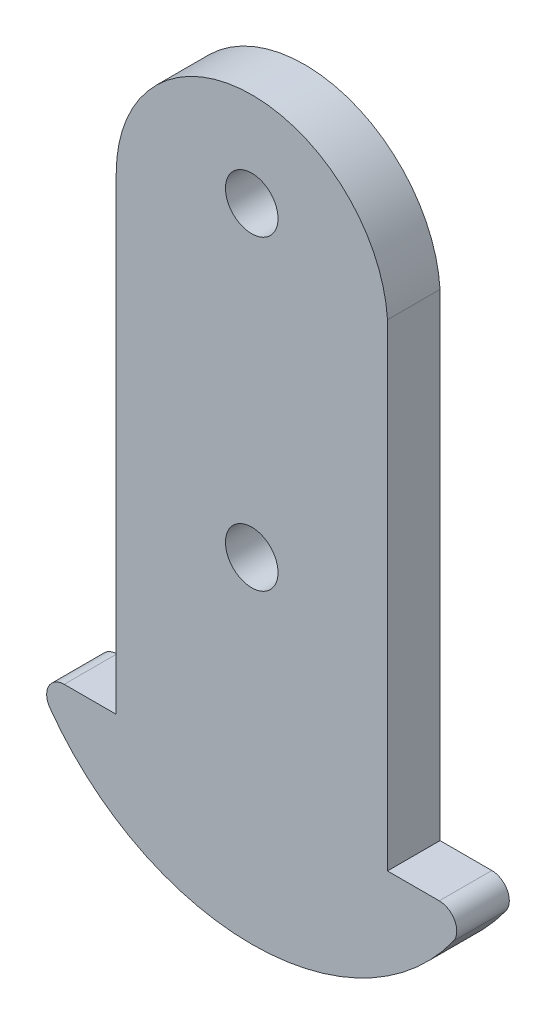
from build123d import *

# Parameters (mm, degrees)
SKETCH1_R           = 1.5
BOSS_EXTRUDE2_DEPTH = 3


with BuildPart() as part:
    # Sketch1 → Boss-Extrude2 (new body)
    with BuildSketch(Plane.XY):
        with BuildLine():
            Line((-7.733855236, 8.750016816), (-7.733855236, -18))
            Line((-7.733855236, -18), (7.75, -18))
            Line((7.75, -18), (7.75, 9.25))
            ThreePointArc((7.75, 9.25), (-0.233977125, 16.495979574), (-7.733855236, 8.750016816))
        make_face()
        with Locations((0, -6.375)):
            Circle(SKETCH1_R, mode=Mode.SUBTRACT)
        with Locations((0, 11.125)):
            Circle(SKETCH1_R, mode=Mode.SUBTRACT)
        with BuildLine():
            ThreePointArc((10.704360482, -18), (11.593820566, -18.542987134), (11.517349886, -19.582278481))
            ThreePointArc((11.517349886, -19.582278481), (0, -25.5), (-11.517349886, -19.582278481))
            ThreePointArc((-11.517349886, -19.582278481), (-11.593820566, -18.542987134), (-10.704360482, -18))
            Line((-10.704360482, -18), (10.704360482, -18))
        make_face()
    extrude(amount=BOSS_EXTRUDE2_DEPTH)


solid = part.part
